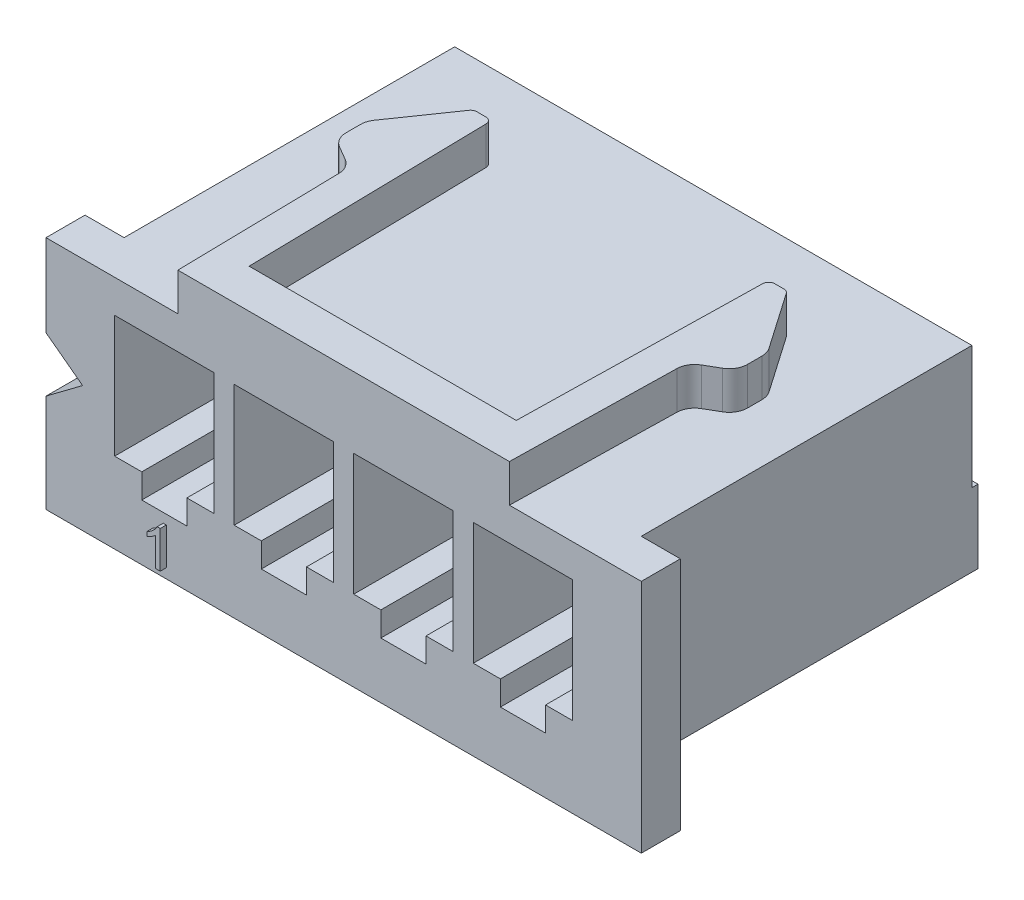
from build123d import *

# Parameters (mm, degrees)
SKETCH1_W                   = 10.7696
SKETCH1_H                   = 4.0894
BODY_DEPTH                  = 7.6962
FLANGE_DEPTH                = 0.8128
LOCK_DEPTH                  = 0.7874
SKETCH4_W                   = 2.0701
SKETCH4_H                   = 2.54
PIN_CAVITY_DEPTH            = 7.0612
SKETCH5_W                   = 0.8001
SKETCH5_H                   = 0.8001
PIN_ENTRY_DEPTH             = 0.635
SKETCH6_W                   = 0.9398
SKETCH6_H                   = 0.508
PIN_LOCK_DEPTH              = 3.175
SKETCH8_W                   = 10.7696
SKETCH8_H                   = 1.524
BODY_EXTEND_DEPTH           = 0.127
SKETCH7_W                   = 1.143
SKETCH7_H                   = 3.048
PIN_CAV_CUTOUT_DEPTH        = 0.889
CHAMFER1_SIZE               = 0.127
F_4_POSITION_COUNT          = 4
F_4_POSITION_PITCH          = 2.4892
CHAMFER1_OF_4_POSITION_SIZE = 0.127
PIN_1_INDICATOR_REACH       = 9.823
PIN_NUMBER_DEPTH            = 0.127


with BuildPart() as part:
    # Sketch1 → BODY (new body)
    with BuildSketch(Plane.XY):
        Rectangle(SKETCH1_W, SKETCH1_H)
    extrude(amount=-BODY_DEPTH)

    # Sketch2 → FLANGE (add)
    with BuildSketch(Plane.XY):
        Polygon((5.3848, -2.0447), (5.3848, 2.0447), (6.1976, 2.0447), (6.1976, -2.8575), (-6.1976, -2.8575), (-6.1976, 2.0447), (-5.3848, 2.0447), (-5.3848, -2.0447), align=None)
    extrude(amount=-FLANGE_DEPTH)

    # Sketch3 → LOCK (add)
    with BuildSketch(Plane(origin=(0, 2.0447, 0), x_dir=(-1, 0, 0), z_dir=(0, 1, 0))):
        with BuildLine():
            Line((-3.451217359, 0), (-3.518566627, -3.417975309))
            ThreePointArc((-3.518566627, -3.417975309), (-3.571148904, -3.603734382), (-3.708036257, -3.739871011))
            Line((-3.708036257, -3.739871011), (-3.988756426, -3.903032559))
            ThreePointArc((-3.988756426, -3.903032559), (-4.12753166, -4.042413008), (-4.1783, -4.232434193))
            Line((-4.1783, -4.232434193), (-4.1783, -4.529184562))
            ThreePointArc((-4.1783, -4.529184562), (-4.160969658, -4.642786409), (-4.110555225, -4.746053564))
            Line((-4.110555225, -4.746053564), (-3.301776384, -5.914289667))
            ThreePointArc((-3.301776384, -5.914289667), (-3.256299524, -5.954493973), (-3.197357976, -5.969))
            Line((-3.197357976, -5.969), (-3.007422189, -5.969))
            ThreePointArc((-3.007422189, -5.969), (-2.918508611, -5.932682829), (-2.880446837, -5.844501977))
            Line((-2.880446837, -5.844501977), (-2.7813, -0.8128))
            Line((-2.7813, -0.8128), (2.7813, -0.8128))
            Line((2.7813, -0.8128), (2.880446837, -5.844501977))
            ThreePointArc((2.880446837, -5.844501977), (2.918508611, -5.932682829), (3.007422189, -5.969))
            Line((3.007422189, -5.969), (3.197357976, -5.969))
            ThreePointArc((3.197357976, -5.969), (3.256299524, -5.954493973), (3.301776384, -5.914289667))
            Line((3.301776384, -5.914289667), (4.110555225, -4.746053564))
            ThreePointArc((4.110555225, -4.746053564), (4.160969658, -4.642786409), (4.1783, -4.529184562))
            Line((4.1783, -4.529184562), (4.1783, -4.232434193))
            ThreePointArc((4.1783, -4.232434193), (4.12753166, -4.042413008), (3.988756426, -3.903032559))
            Line((3.988756426, -3.903032559), (3.708036257, -3.739871011))
            ThreePointArc((3.708036257, -3.739871011), (3.571148904, -3.603734382), (3.518566627, -3.417975309))
            Line((3.518566627, -3.417975309), (3.451217359, 0))
            Line((3.451217359, 0), (-3.451217359, 0))
        make_face()
    extrude(amount=LOCK_DEPTH)

    # Sketch4 → PIN CAVITY (cut)
    with BuildSketch(Plane.XY):
        with Locations((-3.7338, 0.0889)):
            Rectangle(SKETCH4_W, SKETCH4_H)
    pin_cavity = extrude(amount=-PIN_CAVITY_DEPTH, mode=Mode.SUBTRACT)

    # Sketch5 → PIN ENTRY (cut)
    with BuildSketch(Plane.XY.offset(-7.0612)):
        with Locations((-3.7338, 0.4953)):
            Rectangle(SKETCH5_W, SKETCH5_H)
    pin_entry = extrude(amount=-PIN_ENTRY_DEPTH, mode=Mode.SUBTRACT)

    # Sketch6 → PIN LOCK (cut)
    with BuildSketch(Plane.XY):
        with Locations((-3.7338, -1.4351)):
            Rectangle(SKETCH6_W, SKETCH6_H)
    pin_lock = extrude(amount=-PIN_LOCK_DEPTH, mode=Mode.SUBTRACT)

    # Sketch8 → BODY EXTEND (add)
    with BuildSketch(Plane(origin=(0, 0, -7.6962), x_dir=(-1, 0, 0), z_dir=(0, 0, -1))):
        with Locations((0, -1.2827)):
            Rectangle(SKETCH8_W, SKETCH8_H)
    extrude(amount=BODY_EXTEND_DEPTH)

    # Sketch7 → PIN CAV CUTOUT (cut)
    with BuildSketch(Plane.XZ.offset(2.0447)):
        with Locations((-3.7338, -6.2992)):
            Rectangle(SKETCH7_W, SKETCH7_H)
    pin_cav_cutout = extrude(amount=-PIN_CAV_CUTOUT_DEPTH, mode=Mode.SUBTRACT)

    # Chamfer1
    chamfer1_edges = [part.edges().sort_by_distance(p)[0] for p in [
        (-3.7338, 0.09525, -7.6962),
        (-4.13385, 0.4953, -7.6962),
        (-3.7338, 0.89535, -7.6962),
        (-3.33375, 0.4953, -7.6962),
    ]]
    chamfer(chamfer1_edges, length=CHAMFER1_SIZE)

    # 4 POSITION: PIN CAVITY, PIN ENTRY, PIN LOCK, PIN CAV CUTOUT ×4
    with Locations(*[(i * F_4_POSITION_PITCH, 0, 0) for i in range(1, F_4_POSITION_COUNT)]):
        add(pin_cavity, mode=Mode.SUBTRACT)
        add(pin_entry, mode=Mode.SUBTRACT)
        add(pin_lock, mode=Mode.SUBTRACT)
        add(pin_cav_cutout, mode=Mode.SUBTRACT)

    # Chamfer1 of 4 POSITION
    chamfer1_of_4_position_edges = [part.edges().sort_by_distance(p)[0] for p in [
        (-1.2446, 0.09525, -7.6962),
        (-1.64465, 0.4953, -7.6962),
        (-1.2446, 0.89535, -7.6962),
        (-0.84455, 0.4953, -7.6962),
        (1.2446, 0.09525, -7.6962),
        (0.84455, 0.4953, -7.6962),
        (1.2446, 0.89535, -7.6962),
        (1.64465, 0.4953, -7.6962),
        (3.7338, 0.09525, -7.6962),
        (3.33375, 0.4953, -7.6962),
        (3.7338, 0.89535, -7.6962),
        (4.13385, 0.4953, -7.6962),
    ]]
    chamfer(chamfer1_of_4_position_edges, length=CHAMFER1_OF_4_POSITION_SIZE)

    # Sketch9 → PIN 1 INDICATOR (cut, up to next)
    with BuildSketch(Plane.XY, mode=Mode.PRIVATE) as pin_1_indicator_sk1:
        Polygon((-6.1976, 0.3302), (-5.4356, -0.2413), (-6.1976, -0.8128), align=None)
    pin_1_indicator_tool1 = extrude(pin_1_indicator_sk1.sketch, amount=-PIN_1_INDICATOR_REACH, mode=Mode.PRIVATE) & part.part
    add(pin_1_indicator_tool1.solids().sort_by_distance((-5.9436, -0.2413, 0))[0], mode=Mode.SUBTRACT)

    # Sketch10 → PIN NUMBER (add)
    with BuildSketch(Plane.XY):
        with BuildLine():
            Line((-3.692543038, -2.6543), (-3.791324526, -2.6543))
            Line((-3.791324526, -2.6543), (-3.791324526, -2.053893769))
            add(Edge.make_bspline(
                [(-3.791324526, -2.053893769), (-3.797012373, -2.059378997), (-3.808833939, -2.070779444), (-3.828817048, -2.086913922), (-3.851120752, -2.103266899), (-3.875455422, -2.118992116), (-3.900260501, -2.133795711), (-3.924231417, -2.147109269), (-3.946967964, -2.158375769), (-3.961944651, -2.164536336), (-3.969131205, -2.16749248)],
                knots=[0, 0, 0, 0, 2.3696e-05, 4.9249e-05, 7.6971e-05, 0.000106639, 0.000136126, 0.000163621, 0.000188885, 0.000212192, 0.000212192, 0.000212192, 0.000212192], degree=3))
            Line((-3.969131205, -2.16749248), (-3.969131205, -2.076428296))
            add(Edge.make_bspline(
                [(-3.969131205, -2.076428296), (-3.956787556, -2.070071292), (-3.932458956, -2.057542014), (-3.898087905, -2.035902229), (-3.865998831, -2.012443811), (-3.836722936, -1.987171954), (-3.810478961, -1.96133958), (-3.788362783, -1.935273699), (-3.769857373, -1.909929775), (-3.760572857, -1.892255199), (-3.756133621, -1.883804395)],
                knots=[0, 0, 0, 0, 4.1637e-05, 8.2064e-05, 0.000121702, 0.000160776, 0.000197993, 0.000232045, 0.000263265, 0.000291868, 0.000291868, 0.000291868, 0.000291868], degree=3))
            Line((-3.756133621, -1.883804395), (-3.692543038, -1.883804395))
            Line((-3.692543038, -1.883804395), (-3.692543038, -2.6543))
        make_face()
    extrude(amount=PIN_NUMBER_DEPTH)


solid = part.part
